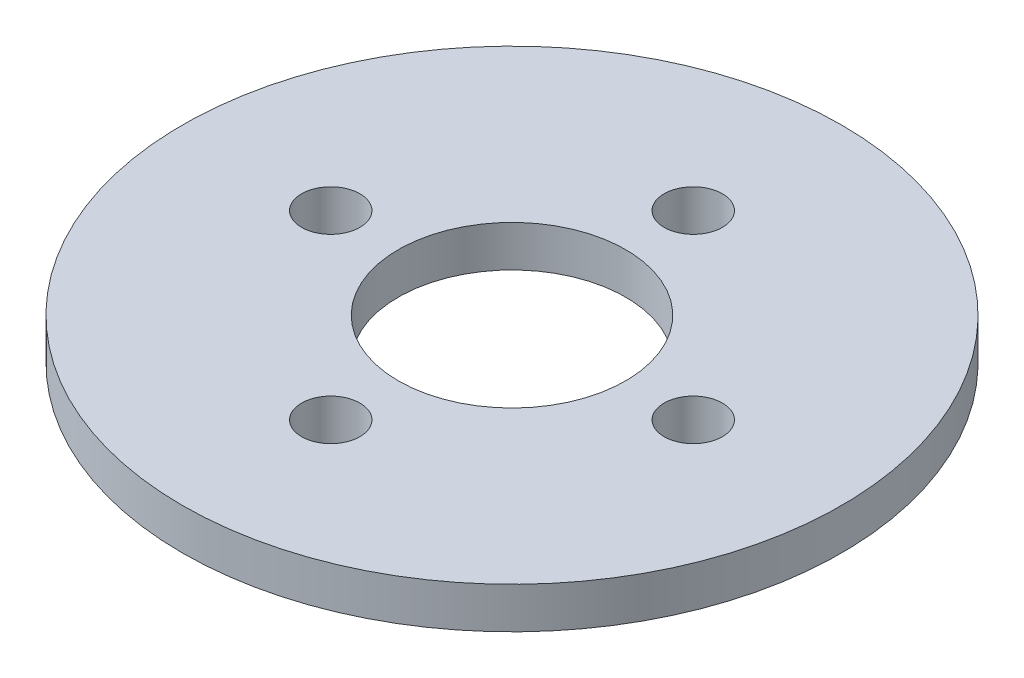
from build123d import *

# Parameters (mm, degrees)
SKETCH1_R             = 25.4
SKETCH1_R_2           = 8.763
BOSS_EXTRUDE1_DEPTH   = 3.175
F_8_CLEARANCE_HOLE1_D = 4.4958


with BuildPart() as part:
    # Sketch1 → Boss-Extrude1 (new body)
    with BuildSketch(Plane(origin=(0, 0, 0), x_dir=(1, 0, 0), z_dir=(0, 1, 0))):
        Circle(SKETCH1_R)
        Circle(SKETCH1_R_2, mode=Mode.SUBTRACT)
    extrude(amount=BOSS_EXTRUDE1_DEPTH)

    # #8 Clearance Hole1 (through all)
    with Locations(Plane(origin=(0, 3.175, 0), x_dir=(1, 0, 0), z_dir=(0, 1, 0))):
        with Locations((13.97, 0), (0, 13.97), (-13.97, 0), (0, -13.97)):
            Hole(F_8_CLEARANCE_HOLE1_D / 2)


solid = part.part
